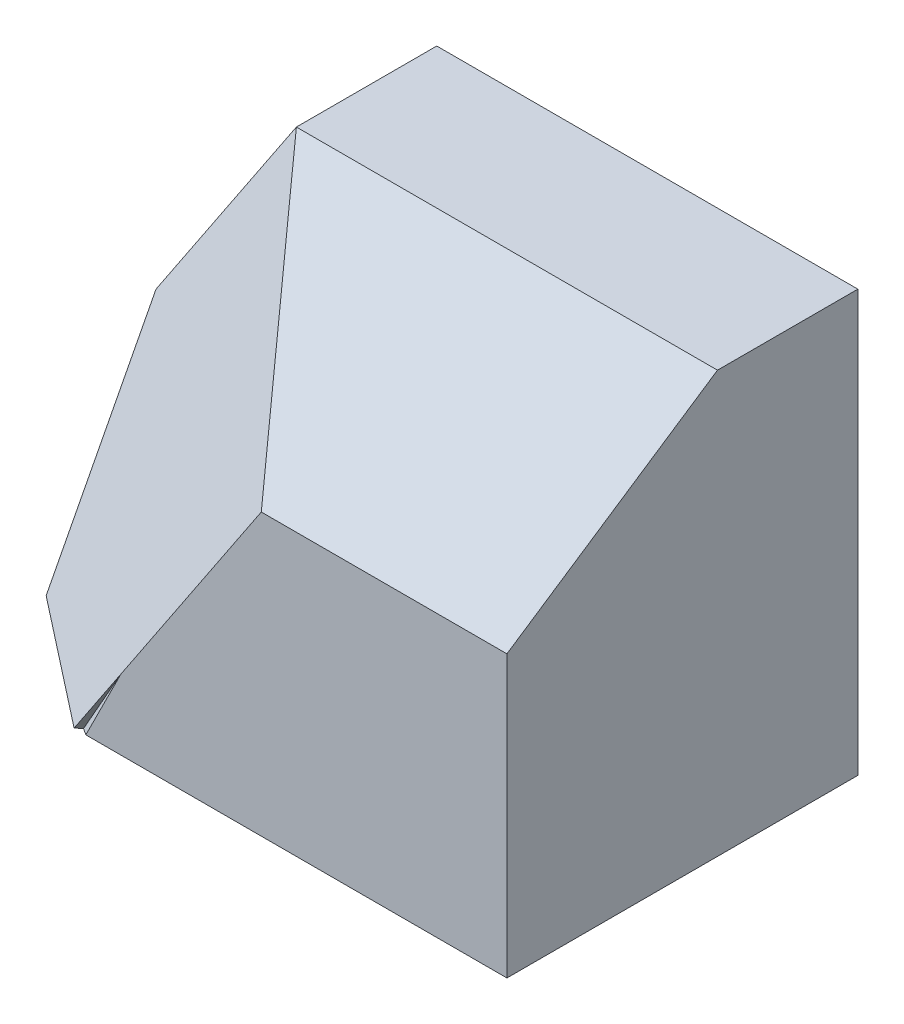
from build123d import *

# Parameters (mm, degrees)
SKETCH1_W           = 80
SKETCH1_H           = 60
BOSS_EXTRUDE1_DEPTH = 50
CUT_EXTRUDE1_DEPTH  = 50
CUT_EXTRUDE2_DEPTH  = 124
CUT_EXTRUDE3_DEPTH  = 124
CUT_EXTRUDE4_DEPTH  = 124
CUT_EXTRUDE5_DEPTH  = 124
CUT_EXTRUDE6_DEPTH  = 124
CUT_EXTRUDE7_DEPTH  = 124
CUT_EXTRUDE8_DEPTH  = 124
CUT_EXTRUDE9_DEPTH  = 124
CUT_EXTRUDE10_DEPTH = 124
CUT_EXTRUDE11_DEPTH = 124
CUT_EXTRUDE12_DEPTH = 124
CUT_EXTRUDE14_DEPTH = 124
CUT_EXTRUDE15_DEPTH = 124
BOSS_EXTRUDE2_DEPTH = 5
SKETCH27_W          = 80
SKETCH27_H          = 50
CUT_EXTRUDE20_DEPTH = 37


with BuildPart() as part:
    # Sketch1 → Boss-Extrude1 (new body)
    with BuildSketch(Plane.XY):
        with Locations((40, 30)):
            Rectangle(SKETCH1_W, SKETCH1_H)
    extrude(amount=BOSS_EXTRUDE1_DEPTH)

    # Sketch2 → Cut-Extrude1 (cut)
    with BuildSketch(Plane.XY.offset(50)):
        Polygon((0, 30), (20, 60), (0, 60), align=None)
    extrude(amount=-CUT_EXTRUDE1_DEPTH, mode=Mode.SUBTRACT)

    # Sketch3 → Cut-Extrude2 (cut)
    with BuildSketch(Plane(origin=(80, 0, 0), x_dir=(0, 0, -1), z_dir=(1, 0, 0))):
        Polygon((-30, 60), (-50, 40), (-50, 60), align=None)
    extrude(amount=-CUT_EXTRUDE2_DEPTH, mode=Mode.SUBTRACT)

    # Sketch6 → Cut-Extrude3 (cut)
    with BuildSketch(Plane(origin=(-15.714285714, 7.857142857, 23.571428571), x_dir=(0.845154255, 0.169030851, 0.507092553), z_dir=(-0.534522484, 0.267261242, 0.801783726))):
        Polygon((42.257712736, 47.434164903), (65.922031869, 22.135943621), (42.257712736, -15.811388301), align=None)
    extrude(amount=CUT_EXTRUDE3_DEPTH, mode=Mode.SUBTRACT)

    # Sketch7 → Cut-Extrude4 (cut)
    with BuildSketch(Plane(origin=(35.714285714, 7.142857143, 21.428571429), x_dir=(0.497245158, 0.099449032, -0.861891607), z_dir=(0.845154255, 0.169030851, 0.507092553))):
        Polygon((-33.149677207, 36.869833406), (-33.149677207, -3.922322703), (-9.944903162, 54.912517839), align=None)
    extrude(amount=-CUT_EXTRUDE4_DEPTH, mode=Mode.SUBTRACT)

    # Sketch8 → Cut-Extrude5 (cut)
    with BuildSketch(Plane(origin=(-16.483516484, -3.296703297, 28.571428571), x_dir=(-0.867610081, 0.056996283, -0.493967783), z_dir=(0.497245158, 0.099449032, -0.861891607))):
        Polygon((-25.736988098, 43.821678207), (-32.829858833, 45.467562834), (-42.05059079, 5.731205399), (-18.998760899, 4.408619538), (-18.998760899, 34.607663372), align=None)
    extrude(amount=-CUT_EXTRUDE5_DEPTH, mode=Mode.SUBTRACT)

    # Sketch9 → Cut-Extrude6 (cut)
    with BuildSketch(Plane(origin=(-22.751322751, 35.264550265, 26.164021164), x_dir=(0.887896271, 0.369460193, 0.274115627), z_dir=(0.460043706, -0.713067745, -0.529050262))):
        Polygon((32.208127825, 14.089089478), (39.138944356, 16.321024445), (48.149005846, -11.657874603), align=None)
    extrude(amount=-CUT_EXTRUDE6_DEPTH, mode=Mode.SUBTRACT)

    # Sketch10 → Cut-Extrude7 (cut)
    with BuildSketch(Plane(origin=(-0.962962963, -2.407407407, 2.407407407), x_dir=(0.962250449, -0.19245009, 0.19245009), z_dir=(0.272165527, 0.680413817, -0.680413817))):
        Polygon((8.581009883, -63.639610307), (7.076241761, -60.15846923), (13.471506281, -63.639610307), align=None)
    extrude(amount=-CUT_EXTRUDE7_DEPTH, mode=Mode.SUBTRACT)

    # Sketch11 → Cut-Extrude8 (cut)
    with BuildSketch(Plane(origin=(-15.346074938, 7.943850556, 1.805420581), x_dir=(-0.092282328, 0.047769676, -0.994586361), z_dir=(0.883262889, -0.457218437, -0.103913281))):
        Polygon((-47.510608217, 39.711812283), (-44.744502297, 37.117331923), (-48.456907611, 37.426149), (-48.456907611, 38.702914935), align=None)
    extrude(amount=-CUT_EXTRUDE8_DEPTH, mode=Mode.SUBTRACT)

    # Sketch12 → Cut-Extrude9 (cut)
    with BuildSketch(Plane(origin=(-7.230769231, 36.153846154, 0), x_dir=(0.980580676, 0.196116135, 0), z_dir=(0.196116135, -0.980580676, 0))):
        Polygon((13.335897189, 50), (13.830048081, 50), (13.335897189, 46.307692308), align=None)
    extrude(amount=-CUT_EXTRUDE9_DEPTH, mode=Mode.SUBTRACT)

    # Sketch15 → Cut-Extrude10 (cut)
    with BuildSketch(Plane(origin=(0, 50.769230769, 33.846153846), x_dir=(-1, 0, 0), z_dir=(0, -0.832050294, -0.554700196))):
        Polygon((-20, 16.641005887), (-80, 16.641005887), (-80, -19.414506868), (-40, -19.414506868), align=None)
    extrude(amount=-CUT_EXTRUDE10_DEPTH, mode=Mode.SUBTRACT)

    # Sketch16 → Cut-Extrude11 (cut)
    with BuildSketch(Plane(origin=(22.352941176, 6.877828054, -10.316742081), x_dir=(-0.385755922, -0.11869413, -0.914933917), z_dir=(0.874474632, 0.269069118, -0.403603676))):
        Polygon((-44.065195676, 50.107704244), (-33.13544456, 51.465023547), (-65.924697908, 26.467726395), align=None)
    extrude(amount=-CUT_EXTRUDE11_DEPTH, mode=Mode.SUBTRACT)

    # Sketch17 → Cut-Extrude12 (cut)
    with BuildSketch(Plane(origin=(-13.474892396, 53.122171946, 6.219181106), x_dir=(0.969698736, 0.242646617, 0.028407409), z_dir=(0.24430383, -0.96312087, -0.112755614))):
        Polygon((39.280526622, 22.819756729), (34.520919906, 12.887590849), (33.567164418, 22.827971688), (35.583149731, 23.962584818), align=None)
    extrude(amount=-CUT_EXTRUDE12_DEPTH, mode=Mode.SUBTRACT)

    # Sketch22 → Cut-Extrude14 (cut)
    with BuildSketch(Plane(origin=(-14.80441324, 9.869608826, 18.916750251), x_dir=(0.821599096, 0.263693024, 0.505411628), z_dir=(-0.57006572, 0.380043813, 0.728417309))):
        Polygon((42.361795907, 43.943770636), (72.790261699, 12.335093512), (40.333231521, -23.128300335), (18.019023273, 17.346225251), align=None)
    extrude(amount=CUT_EXTRUDE14_DEPTH, mode=Mode.SUBTRACT)

    # Sketch23 → Cut-Extrude15 (cut)
    with BuildSketch(Plane(origin=(17.379185671, 15.917127194, 5.296513728), x_dir=(0.161703891, 0.148100231, -0.97566294), z_dir=(0.719498347, 0.658969121, 0.219275687))):
        Polygon((-15.07025189, 22.123368133), (-22.755667886, 20.283347912), (-41.425957995, -7.45305002), align=None)
    extrude(amount=-CUT_EXTRUDE15_DEPTH, mode=Mode.SUBTRACT)

    # Sketch26 → Boss-Extrude2 (add)
    with BuildSketch(Plane(origin=(-14.80441324, 9.869608826, 18.916750251), x_dir=(0.821599096, 0.263693024, 0.505411628), z_dir=(-0.57006572, 0.380043813, 0.728417309))):
        Polygon((18.019023273, -16.491483717), (40.333231521, -23.128300335), (72.790261699, 12.335093512), (42.361795907, 43.943770636), (18.019023273, 17.346225251), align=None)
    extrude(amount=-BOSS_EXTRUDE2_DEPTH)

    # Sketch27 → Cut-Extrude20 (cut)
    with BuildSketch(Plane.XZ):
        with Locations((40, 25)):
            Rectangle(SKETCH27_W, SKETCH27_H)
    extrude(amount=CUT_EXTRUDE20_DEPTH, mode=Mode.SUBTRACT)


solid = part.part
